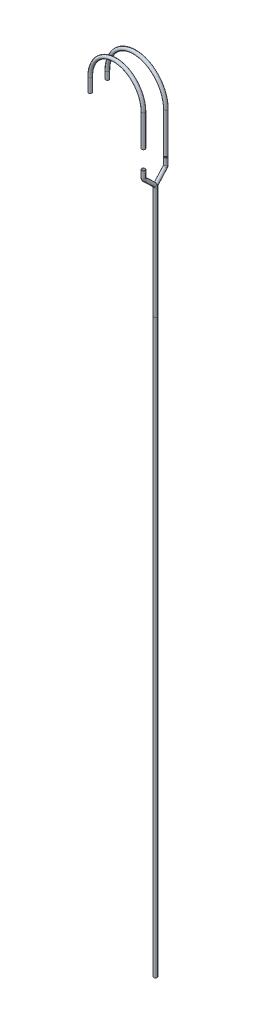
from build123d import *

# Parameters (mm, degrees)
SWEEP_THIN1_PROFILE_R   = 30
SWEEP_THIN1_PROFILE_R_2 = 27
SWEEP_THIN2_PROFILE_R   = 31
SWEEP_THIN2_PROFILE_R_2 = 30
SWEEP_THIN3_PROFILE_R   = 30
SWEEP_THIN3_PROFILE_R_2 = 27
SWEEP_THIN4_PROFILE_R   = 30
SWEEP_THIN4_PROFILE_R_2 = 27
SWEEP_THIN5_PROFILE_R   = 30
SWEEP_THIN5_PROFILE_R_2 = 27


with BuildPart() as part:
    # Sweep-Thin1: sweep along a curve in space
    with BuildLine() as sweep_thin1_path:
        Line((-29315.912148977, -4333.730929332, 41797.542162608), (-29315.912148977, 5869.932948431, 41797.542162608))
    # Sweep-Thin1 profile (on start of the path) → Sweep-Thin1 (sweep)
    with BuildSketch(Plane(origin=(-29315.912148977, -4333.730929332, 41797.542162608), x_dir=(1, 0, 0), z_dir=(0, 1, 0))):
        Circle(SWEEP_THIN1_PROFILE_R)
        Circle(SWEEP_THIN1_PROFILE_R_2, mode=Mode.SUBTRACT)
    sweep(path=sweep_thin1_path.line)


with BuildPart() as body_2:
    # Sweep-Thin2: sweep along a curve in space
    with BuildLine() as sweep_thin2_path:
        Line((-29315.912148977, 5869.932948431, 41797.542162608), (-29315.912148978, 7869.932948431, 41797.542162608))
        ThreePointArc((-29315.912148978, 7869.932948431, 41797.542162608), (-29316.156185574, 7889.672909103, 41801.596453456), (-29316.848647923, 7906.2058141, 41813.100645029))
        Line((-29316.848647923, 7906.2058141, 41813.100645029), (-29327.091819815, 8067.948597198, 41983.275112988))
        ThreePointArc((-29327.091819815, 8067.948597198, 41983.275112988), (-29327.784282163, 8084.481502195, 41994.779304561), (-29328.028318761, 8104.221462868, 41998.83359541))
        Line((-29328.028318761, 8104.221462868, 41998.83359541), (-29328.028318761, 8229.221462868, 41998.83359541))
    # Sweep-Thin2 profile (on start of the path) → Sweep-Thin2 (sweep)
    with BuildSketch(Plane(origin=(-29315.912148977, 5869.932948431, 41797.542162608), x_dir=(1, 0, 0), z_dir=(0, 1, 0))):
        Circle(SWEEP_THIN2_PROFILE_R)
        Circle(SWEEP_THIN2_PROFILE_R_2, mode=Mode.SUBTRACT)
    sweep(path=sweep_thin2_path.line)


with BuildPart() as body_3:
    # Sweep-Thin3: sweep along a curve in space
    with BuildLine() as sweep_thin3_path:
        Line((-29315.912148977, 5869.932948432, 41797.542162608), (-29315.912148977, 7869.932948432, 41797.542162607))
        ThreePointArc((-29316.80681384, 7905.288287491, 41782.924855439), (-29316.1446648, 7889.06712005, 41793.743248247), (-29315.912148977, 7869.932948432, 41797.542162607))
        Line((-29316.80681384, 7905.288287491, 41782.924855439), (-29327.133653897, 8074.327083449, 41614.201795625))
        ThreePointArc((-29327.133653897, 8074.327083449, 41614.201795625), (-29327.795802938, 8090.54825089, 41603.383402817), (-29328.028318761, 8109.682422508, 41599.584488457))
        Line((-29328.028318761, 8109.682422508, 41599.584488457), (-29328.028318761, 8229.221462868, 41599.584488457))
    # Sweep-Thin3 profile (on start of the path) → Sweep-Thin3 (sweep)
    with BuildSketch(Plane(origin=(-29315.912148977, 5869.932948432, 41797.542162608), x_dir=(1, 0, 0), z_dir=(0, 1, 0))):
        Circle(SWEEP_THIN3_PROFILE_R)
        Circle(SWEEP_THIN3_PROFILE_R_2, mode=Mode.SUBTRACT)
    sweep(path=sweep_thin3_path.line)


with BuildPart() as body_4:
    # Sweep-Thin4: sweep along a curve in space
    with BuildLine() as sweep_thin4_path:
        Line((-29328.028318761, 8554.238502035, 41998.83359541), (-29328.028318761, 9119.915610551, 41998.83359541))
        ThreePointArc((-29328.028318761, 9119.915610551, 41998.83359541), (-29838.299853656, 9631.396043593, 41963.688267696), (-30348.571388551, 9119.915610551, 41928.542939982))
        Line((-30348.571388551, 9119.915610551, 41928.542939982), (-30348.571388551, 8877.040121217, 41928.542939982))
    # Sweep-Thin4 profile (on start of the path) → Sweep-Thin4 (sweep)
    with BuildSketch(Plane(origin=(-29328.028318761, 8554.238502035, 41998.83359541), x_dir=(0, 0, 1), z_dir=(0, 1, 0))):
        Circle(SWEEP_THIN4_PROFILE_R)
        Circle(SWEEP_THIN4_PROFILE_R_2, mode=Mode.SUBTRACT)
    sweep(path=sweep_thin4_path.line)


with BuildPart() as body_5:
    # Sweep-Thin5: sweep along a curve in space
    with BuildLine() as sweep_thin5_path:
        Line((-30449.026480145, 8963.286722, 41521.626698613), (-30449.026480145, 8827.276106778, 41521.626698613))
        ThreePointArc((-29328.028318761, 8963.286722, 41599.584488457), (-29888.527399453, 9525.139526306, 41560.605593535), (-30449.026480145, 8963.286722, 41521.626698613))
        Line((-29328.028318761, 8249.090823585, 41599.584488457), (-29328.028318761, 8963.286722, 41599.584488457))
    # Sweep-Thin5 profile (on start of the path) → Sweep-Thin5 (sweep)
    with BuildSketch(Plane(origin=(-29328.028318761, 8249.090823585, 41599.584488457), x_dir=(0, 0, 1), z_dir=(0, 1, 0))):
        Circle(SWEEP_THIN5_PROFILE_R)
        Circle(SWEEP_THIN5_PROFILE_R_2, mode=Mode.SUBTRACT)
    sweep(path=sweep_thin5_path.line)


solid = Compound([part.part, body_2.part, body_3.part, body_4.part, body_5.part])
